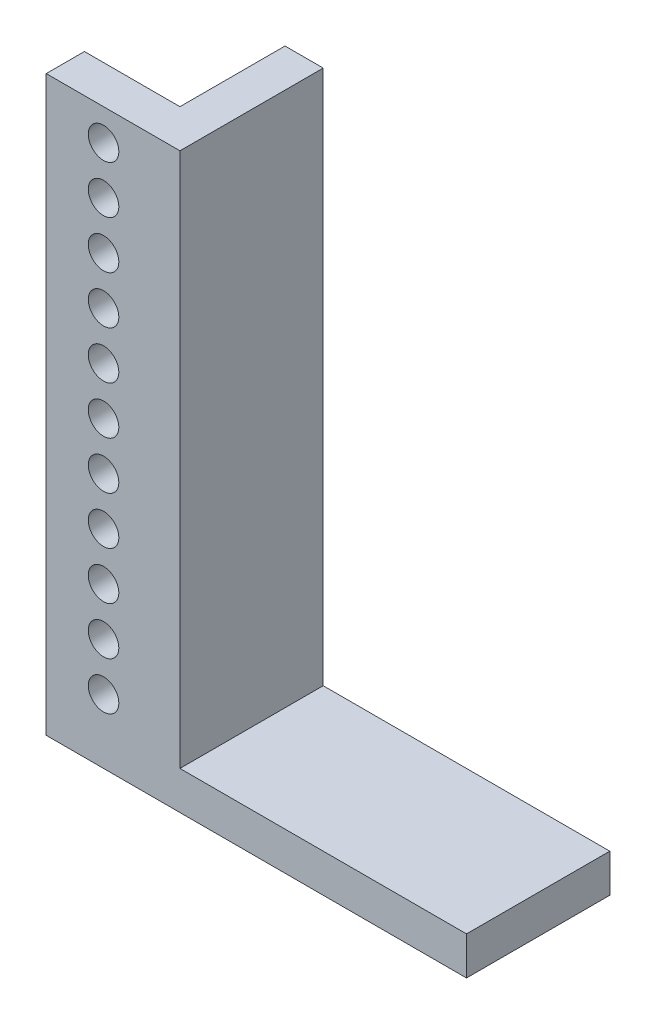
from build123d import *

# Parameters (mm, degrees)
EXTRUDE_1_DEPTH     = 15
SKETCH_2_W          = 4
SKETCH_2_H          = 60
EXTRUDE_2_DEPTH     = 10
SKETCH_3_R          = 1.6
CUT_EXTRUDE_1_DEPTH = 6


with BuildPart() as part:
    # ｽｹｯﾁ1 → ﾎﾞｽ - 押し出し1 (new body)
    with BuildSketch(Plane.XY):
        Polygon((-37.26940162, 16.179775281), (-33.26940162, 16.179775281), (-33.26940162, -39.820224719), (-3.26940162, -39.820224719), (-3.26940162, -43.820224719), (-37.26940162, -43.820224719), align=None)
    extrude(amount=EXTRUDE_1_DEPTH)

    # ｽｹｯﾁ2 → ﾎﾞｽ - 押し出し2 (add)
    with BuildSketch(Plane.ZY.offset(37.26940162)):
        with Locations((13, -13.820224719)):
            Rectangle(SKETCH_2_W, SKETCH_2_H)
    extrude(amount=EXTRUDE_2_DEPTH)

    # ｽｹｯﾁ3 → ｶｯﾄ - 押し出し1 (cut)
    with BuildSketch(Plane.XY.offset(15)):
        with Locations((-41.26940162, 7.900067142)):
            Circle(SKETCH_3_R)
        with Locations((-41.26940162, 2.900067142)):
            Circle(SKETCH_3_R)
        with Locations((-41.26940162, -2.099932858)):
            Circle(SKETCH_3_R)
        with Locations((-41.26940162, -7.099932858)):
            Circle(SKETCH_3_R)
        with Locations((-41.26940162, -12.099932858)):
            Circle(SKETCH_3_R)
        with Locations((-41.26940162, -17.099932858)):
            Circle(SKETCH_3_R)
        with Locations((-41.26940162, -22.099932858)):
            Circle(SKETCH_3_R)
        with Locations((-41.26940162, -27.099932858)):
            Circle(SKETCH_3_R)
        with Locations((-41.26940162, -32.099932858)):
            Circle(SKETCH_3_R)
        with Locations((-41.26940162, -37.099932858)):
            Circle(SKETCH_3_R)
        with Locations((-41.26940162, 12.900067142)):
            Circle(SKETCH_3_R)
    extrude(amount=-CUT_EXTRUDE_1_DEPTH, mode=Mode.SUBTRACT)


solid = part.part
